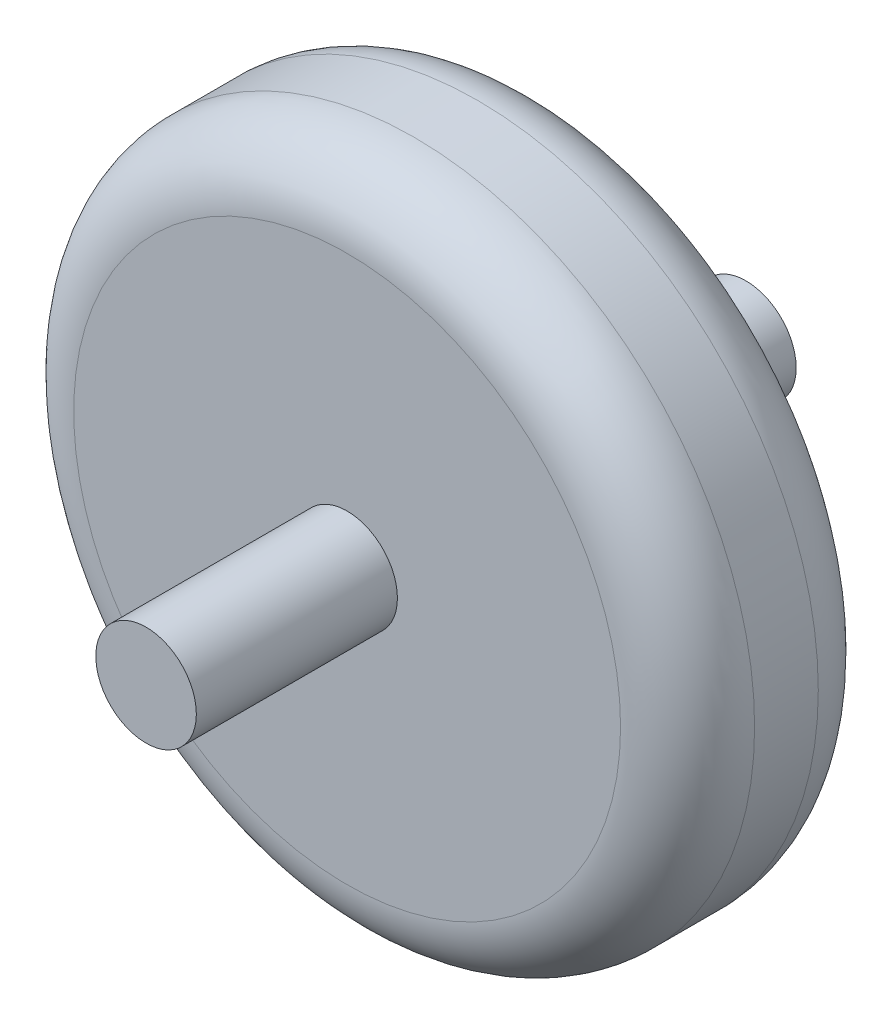
from build123d import *

# Parameters (mm, degrees)
SKETCH1_R                = 101.6
BOSS_EXTRUDE1_DEPTH      = 59
FILLET1_R                = 20
SKETCH2_R                = 15
BOSS_EXTRUDE2_DEPTH      = 60
BOSS_EXTRUDE2_DEPTH_BACK = 119


with BuildPart() as part:
    # Sketch1 → Boss-Extrude1 (new body)
    with BuildSketch(Plane.XY):
        Circle(SKETCH1_R)
    extrude(amount=BOSS_EXTRUDE1_DEPTH)

    # Fillet1
    fillet1_edges = [part.edges().sort_by_distance(p)[0] for p in [
        (-101.6, 0, 0),
        (-101.6, 0, 59),
    ]]
    fillet(fillet1_edges, radius=FILLET1_R)

    # Sketch2 → Boss-Extrude2 (add, two sides)
    with BuildSketch(Plane.XY.offset(59)) as boss_extrude2_sk:
        Circle(SKETCH2_R)
    extrude(amount=BOSS_EXTRUDE2_DEPTH)
    extrude(boss_extrude2_sk.sketch, amount=-BOSS_EXTRUDE2_DEPTH_BACK)


solid = part.part
